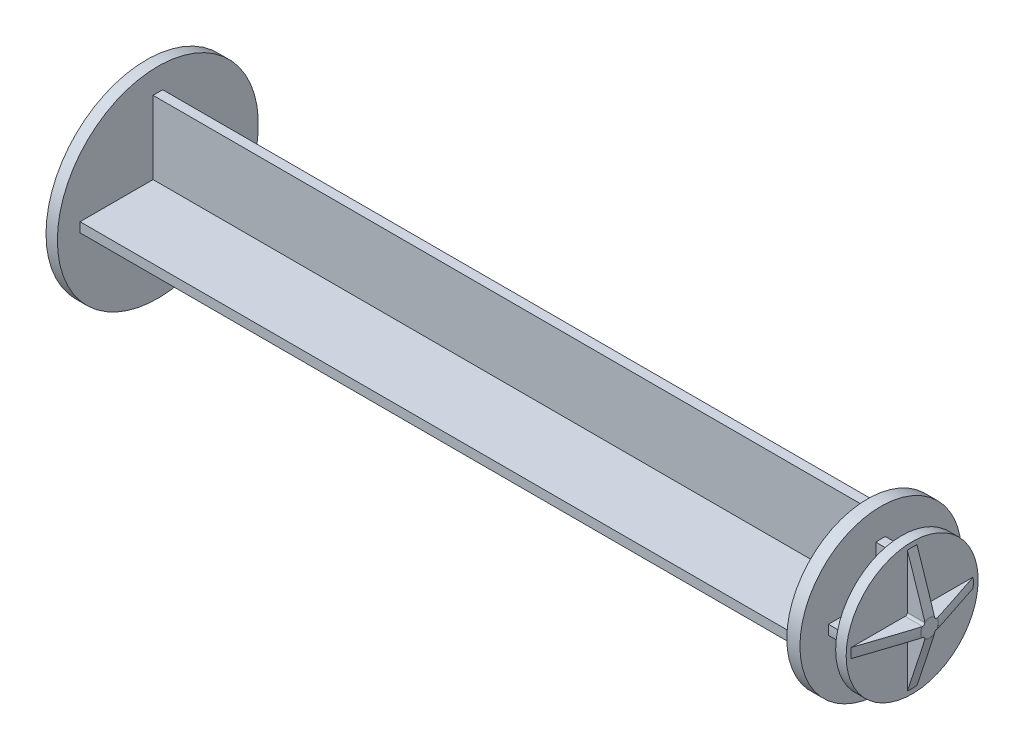
from build123d import *

# Parameters (mm, degrees)
SKETCH2_OUTSIDE_W                   = 55.422
SKETCH2_OUTSIDE_H                   = 55.422
CUT_EXTRUDE_PUSHER_SIDE_CROSS_DEPTH = 103.124
CUT_EXTRUDE_CROSS_2_DEPTH           = 3.048
SKETCH8_OUTSIDE_W                   = 55.422
SKETCH8_OUTSIDE_H                   = 55.422
CUT_EXTRUDE1_DEPTH                  = 3.54


with BuildPart() as part:
    # Sketch1 → Revolve: Main Body (revolve)
    with BuildSketch(Plane.XY):
        with BuildLine():
            Line((0, 0), (0, 14.605))
            Line((0, 14.605), (1.651, 14.605))
            Line((1.651, 14.605), (1.651, 11.7348))
            Line((1.651, 11.7348), (106.68, 11.7348))
            Line((106.68, 11.7348), (106.68, 9.5885))
            Line((106.68, 9.5885), (111.252, 9.5885))
            Line((111.252, 9.5885), (111.252, 8.89))
            Line((111.252, 8.89), (113.775706947, 1.318879159))
            ThreePointArc((113.775706947, 1.318879159), (113.787900268, 1.269334705), (113.792, 1.218476843))
            Line((113.792, 1.218476843), (113.792, 0))
            Line((113.792, 0), (0, 0))
        make_face()
    revolve(axis=Axis((-3.305576832, 0, 0), (1, 0, 0)))

    # Sketch2 outside → Cut-Extrude: Pusher Side Cross (cut)
    with BuildSketch(Plane(origin=(1.651, 0, 0), x_dir=(0, 0, -1), z_dir=(1, 0, 0))):
        Rectangle(SKETCH2_OUTSIDE_W, SKETCH2_OUTSIDE_H)
        Polygon((-0.6985, 11.303), (0.6985, 11.303), (0.6985, 0.6985), (11.303, 0.6985), (11.303, -0.6985), (0.6985, -0.6985), (0.6985, -11.303), (-0.6985, -11.303), (-0.6985, -0.6985), (-11.303, -0.6985), (-11.303, 0.6985), (-0.6985, 0.6985), align=None, mode=Mode.SUBTRACT)
    extrude(amount=CUT_EXTRUDE_PUSHER_SIDE_CROSS_DEPTH, mode=Mode.SUBTRACT)

    # Sketch3 → Cut-Extrude: Cross 2 (cut)
    with BuildSketch(Plane(origin=(106.68, 0, 0), x_dir=(0, 0, -1), z_dir=(1, 0, 0))):
        with BuildLine():
            Line((-11.713992863, 0.6985), (-9.563024103, 0.6985))
            ThreePointArc((-9.563024103, 0.6985), (-6.780093371, 6.780093371), (-0.6985, 9.563024103))
            Line((-0.6985, 9.563024103), (-0.6985, 11.713992863))
            ThreePointArc((-0.6985, 11.713992863), (-8.297756656, 8.297756656), (-11.713992863, 0.6985))
        make_face()
        with BuildLine():
            Line((0.6985, 11.713992863), (0.6985, 9.563024103))
            ThreePointArc((0.6985, 9.563024103), (6.780093371, 6.780093371), (9.563024103, 0.6985))
            Line((9.563024103, 0.6985), (11.713992863, 0.6985))
            ThreePointArc((11.713992863, 0.6985), (8.297756656, 8.297756656), (0.6985, 11.713992863))
        make_face()
        with BuildLine():
            ThreePointArc((9.563024103, -0.6985), (6.780093371, -6.780093371), (0.6985, -9.563024103))
            Line((0.6985, -9.563024103), (0.6985, -11.713992863))
            ThreePointArc((0.6985, -11.713992863), (8.297756656, -8.297756656), (11.713992863, -0.6985))
            Line((11.713992863, -0.6985), (9.563024103, -0.6985))
        make_face()
        with BuildLine():
            ThreePointArc((-0.6985, -9.563024103), (-6.780093371, -6.780093371), (-9.563024103, -0.6985))
            Line((-9.563024103, -0.6985), (-11.713992863, -0.6985))
            ThreePointArc((-11.713992863, -0.6985), (-8.297756656, -8.297756656), (-0.6985, -11.713992863))
            Line((-0.6985, -11.713992863), (-0.6985, -9.563024103))
        make_face()
        with BuildLine():
            Line((-9.563024103, 0.6985), (-7.58791788, 0.6985))
            Line((-7.58791788, 0.6985), (-0.6985, 0.6985))
            Line((-0.6985, 0.6985), (-0.6985, 7.58791788))
            Line((-0.6985, 7.58791788), (-0.6985, 9.563024103))
            ThreePointArc((-0.6985, 9.563024103), (-6.780093371, 6.780093371), (-9.563024103, 0.6985))
        make_face()
        with BuildLine():
            Line((0.6985, 9.563024103), (0.6985, 7.58791788))
            Line((0.6985, 7.58791788), (0.6985, 0.6985))
            Line((0.6985, 0.6985), (7.58791788, 0.6985))
            Line((7.58791788, 0.6985), (9.563024103, 0.6985))
            ThreePointArc((9.563024103, 0.6985), (6.780093371, 6.780093371), (0.6985, 9.563024103))
        make_face()
        with BuildLine():
            Line((0.6985, -7.58791788), (0.6985, -9.563024103))
            ThreePointArc((0.6985, -9.563024103), (6.780093371, -6.780093371), (9.563024103, -0.6985))
            Line((9.563024103, -0.6985), (7.58791788, -0.6985))
            Line((7.58791788, -0.6985), (0.6985, -0.6985))
            Line((0.6985, -0.6985), (0.6985, -7.58791788))
        make_face()
        with BuildLine():
            Line((-0.6985, -0.6985), (-7.58791788, -0.6985))
            Line((-7.58791788, -0.6985), (-9.563024103, -0.6985))
            ThreePointArc((-9.563024103, -0.6985), (-6.780093371, -6.780093371), (-0.6985, -9.563024103))
            Line((-0.6985, -9.563024103), (-0.6985, -7.58791788))
            Line((-0.6985, -7.58791788), (-0.6985, -0.6985))
        make_face()
        with BuildLine():
            Line((-0.6985, -7.58791788), (-0.6985, -9.563024103))
            ThreePointArc((-0.6985, -9.563024103), (0, -9.5885), (0.6985, -9.563024103))
            Line((0.6985, -9.563024103), (0.6985, -7.58791788))
            ThreePointArc((0.6985, -7.58791788), (0, -7.62), (-0.6985, -7.58791788))
        make_face()
        with BuildLine():
            Line((-0.6985, 9.563024103), (-0.6985, 7.58791788))
            ThreePointArc((-0.6985, 7.58791788), (0, 7.62), (0.6985, 7.58791788))
            Line((0.6985, 7.58791788), (0.6985, 9.563024103))
            ThreePointArc((0.6985, 9.563024103), (0, 9.5885), (-0.6985, 9.563024103))
        make_face()
        with BuildLine():
            Line((-0.6985, 11.713992863), (-0.6985, 9.563024103))
            ThreePointArc((-0.6985, 9.563024103), (0, 9.5885), (0.6985, 9.563024103))
            Line((0.6985, 9.563024103), (0.6985, 11.713992863))
            ThreePointArc((0.6985, 11.713992863), (0, 11.7348), (-0.6985, 11.713992863))
        make_face()
        with BuildLine():
            ThreePointArc((0.6985, -9.563024103), (0, -9.5885), (-0.6985, -9.563024103))
            Line((-0.6985, -9.563024103), (-0.6985, -11.713992863))
            ThreePointArc((-0.6985, -11.713992863), (0, -11.7348), (0.6985, -11.713992863))
            Line((0.6985, -11.713992863), (0.6985, -9.563024103))
        make_face()
        with BuildLine():
            Line((11.713992863, 0.6985), (9.563024103, 0.6985))
            ThreePointArc((9.563024103, 0.6985), (9.582128909, 0.349482214), (9.5885, 0))
            ThreePointArc((9.5885, 0), (9.582128909, -0.349482214), (9.563024103, -0.6985))
            Line((9.563024103, -0.6985), (11.713992863, -0.6985))
            ThreePointArc((11.713992863, -0.6985), (11.729597062, -0.349404918), (11.7348, 0))
            ThreePointArc((11.7348, 0), (11.729597062, 0.349404918), (11.713992863, 0.6985))
        make_face()
        with BuildLine():
            ThreePointArc((9.5885, 0), (9.582128909, 0.349482214), (9.563024103, 0.6985))
            Line((9.563024103, 0.6985), (7.58791788, 0.6985))
            ThreePointArc((7.58791788, 0.6985), (7.62, 0), (7.58791788, -0.6985))
            Line((7.58791788, -0.6985), (9.563024103, -0.6985))
            ThreePointArc((9.563024103, -0.6985), (9.582128909, -0.349482214), (9.5885, 0))
        make_face()
        with BuildLine():
            ThreePointArc((-7.58791788, -0.6985), (-7.62, 0), (-7.58791788, 0.6985))
            Line((-7.58791788, 0.6985), (-9.563024103, 0.6985))
            ThreePointArc((-9.563024103, 0.6985), (-9.5885, 0), (-9.563024103, -0.6985))
            Line((-9.563024103, -0.6985), (-7.58791788, -0.6985))
        make_face()
        with BuildLine():
            ThreePointArc((-9.563024103, -0.6985), (-9.5885, 0), (-9.563024103, 0.6985))
            Line((-9.563024103, 0.6985), (-11.713992863, 0.6985))
            ThreePointArc((-11.713992863, 0.6985), (-11.7348, 0), (-11.713992863, -0.6985))
            Line((-11.713992863, -0.6985), (-9.563024103, -0.6985))
        make_face()
    extrude(amount=CUT_EXTRUDE_CROSS_2_DEPTH, mode=Mode.SUBTRACT)

    # Sketch8 outside → Cut-Extrude1 (cut, through all)
    with BuildSketch(Plane(origin=(111.252, 0, 0), x_dir=(0, 0, -1), z_dir=(1, 0, 0))):
        Rectangle(SKETCH8_OUTSIDE_W, SKETCH8_OUTSIDE_H)
        with BuildLine():
            Line((-0.6985, -14.588287177), (0.6985, -14.588287177))
            Line((0.6985, -14.588287177), (0.6985, -1.016))
            ThreePointArc((0.6985, -1.016), (0.791493597, -0.791493597), (1.016, -0.6985))
            Line((1.016, -0.6985), (14.588287177, -0.6985))
            Line((14.588287177, -0.6985), (14.588287177, 0.6985))
            Line((14.588287177, 0.6985), (1.016, 0.6985))
            ThreePointArc((1.016, 0.6985), (0.791493597, 0.791493597), (0.6985, 1.016))
            Line((0.6985, 1.016), (0.6985, 14.588287177))
            Line((0.6985, 14.588287177), (-0.6985, 14.588287177))
            Line((-0.6985, 14.588287177), (-0.6985, 1.016))
            ThreePointArc((-0.6985, 1.016), (-0.791493597, 0.791493597), (-1.016, 0.6985))
            Line((-1.016, 0.6985), (-14.588287177, 0.6985))
            Line((-14.588287177, 0.6985), (-14.588287177, -0.6985))
            Line((-14.588287177, -0.6985), (-1.016, -0.6985))
            ThreePointArc((-1.016, -0.6985), (-0.791493597, -0.791493597), (-0.6985, -1.016))
            Line((-0.6985, -1.016), (-0.6985, -14.588287177))
        make_face(mode=Mode.SUBTRACT)
    extrude(amount=CUT_EXTRUDE1_DEPTH, mode=Mode.SUBTRACT)


solid = part.part
